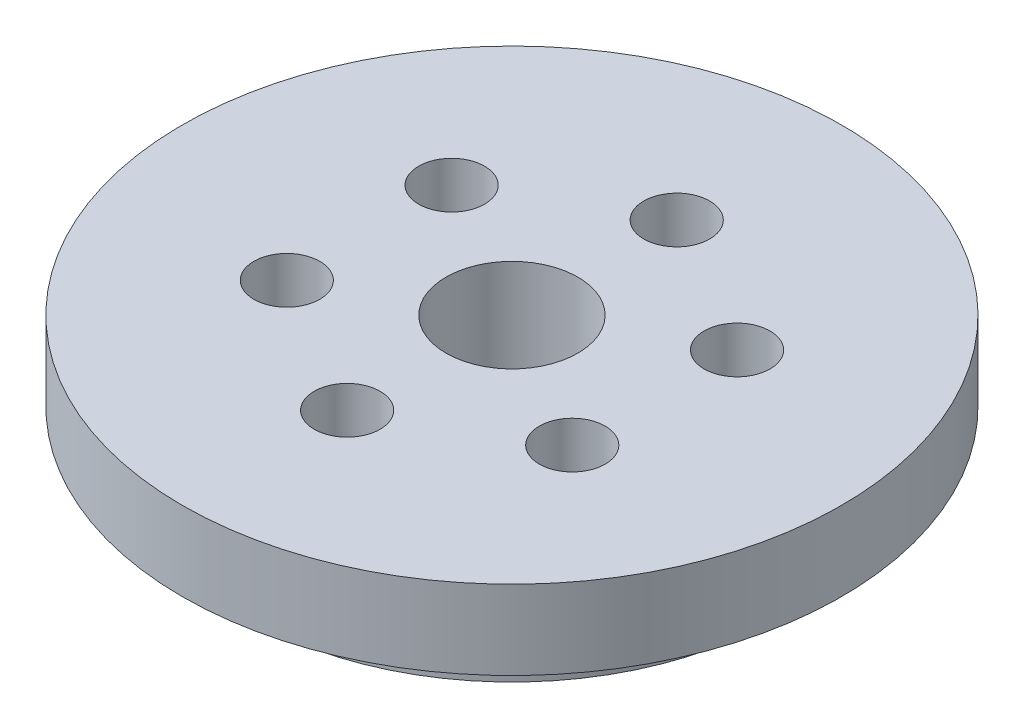
from build123d import *

# Parameters (mm, degrees)
ESQUISSE1_R        = 19.95
ESQUISSE1_R_2      = 5
ESQUISSE1_R_3      = 2.5
BOSS_EXTRU_1_DEPTH = 4
ESQUISSE2_R        = 25
ESQUISSE2_R_2      = 2.5
ESQUISSE2_R_3      = 5
BOSS_EXTRU_2_DEPTH = 6


with BuildPart() as part:
    # Esquisse1 → Boss.-Extru.1 (new body)
    with BuildSketch(Plane(origin=(0, 0, 0), x_dir=(1, 0, 0), z_dir=(0, 1, 0))):
        Circle(ESQUISSE1_R)
        Circle(ESQUISSE1_R_2, mode=Mode.SUBTRACT)
        with Locations((0, 12.5)):
            Circle(ESQUISSE1_R_3, mode=Mode.SUBTRACT)
        with Locations((10.825317547, 6.25)):
            Circle(ESQUISSE1_R_3, mode=Mode.SUBTRACT)
        with Locations((10.825317547, -6.25)):
            Circle(ESQUISSE1_R_3, mode=Mode.SUBTRACT)
        with Locations((0, -12.5)):
            Circle(ESQUISSE1_R_3, mode=Mode.SUBTRACT)
        with Locations((-10.825317547, -6.25)):
            Circle(ESQUISSE1_R_3, mode=Mode.SUBTRACT)
        with Locations((-10.825317547, 6.25)):
            Circle(ESQUISSE1_R_3, mode=Mode.SUBTRACT)
    extrude(amount=BOSS_EXTRU_1_DEPTH)

    # Esquisse2 → Boss.-Extru.2 (add)
    with BuildSketch(Plane(origin=(0, 4, 0), x_dir=(1, 0, 0), z_dir=(0, 1, 0))):
        Circle(ESQUISSE2_R)
        with Locations((0, 12.5)):
            Circle(ESQUISSE2_R_2, mode=Mode.SUBTRACT)
        with Locations((10.825317547, 6.25)):
            Circle(ESQUISSE2_R_2, mode=Mode.SUBTRACT)
        with Locations((10.825317547, -6.25)):
            Circle(ESQUISSE2_R_2, mode=Mode.SUBTRACT)
        Circle(ESQUISSE2_R_3, mode=Mode.SUBTRACT)
        with Locations((0, -12.5)):
            Circle(ESQUISSE2_R_2, mode=Mode.SUBTRACT)
        with Locations((-10.825317547, -6.25)):
            Circle(ESQUISSE2_R_2, mode=Mode.SUBTRACT)
        with Locations((-10.825317547, 6.25)):
            Circle(ESQUISSE2_R_2, mode=Mode.SUBTRACT)
    extrude(amount=BOSS_EXTRU_2_DEPTH)


solid = part.part
